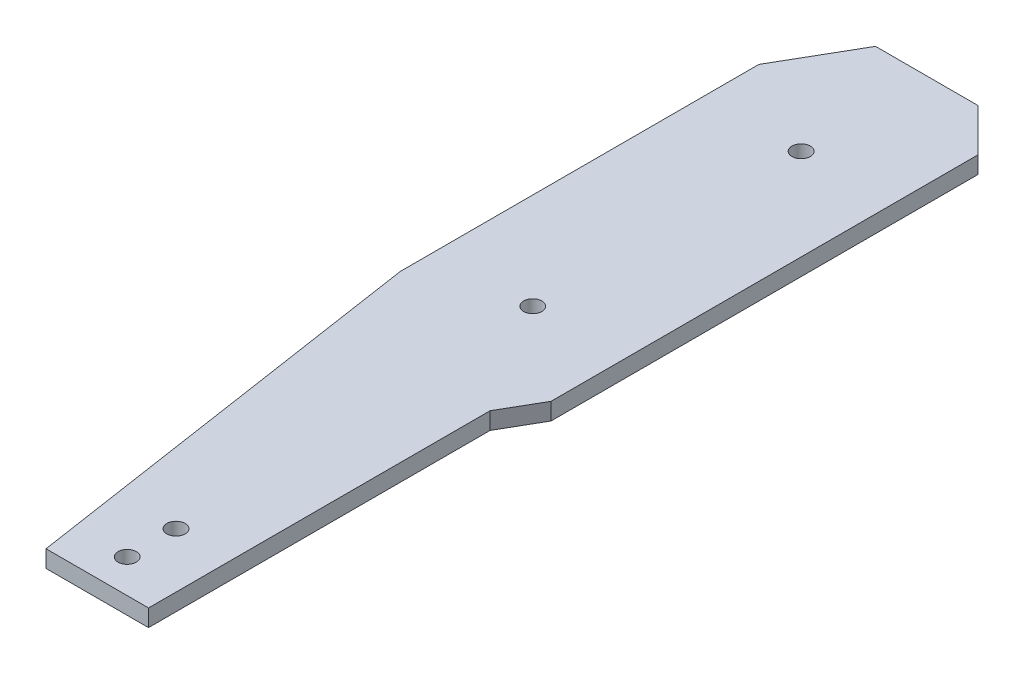
from build123d import *

# Parameters (mm, degrees)
BOSS_EXTRUDE1_DEPTH = 2
SCALE1_SCALE        = 1.4
SKETCH2_R           = 1.5
CUT_EXTRUDE1_DEPTH  = 3.8
SKETCH3_R           = 1.5
CUT_EXTRUDE2_DEPTH  = 3.8


with BuildPart() as part:
    # Sketch1 → Boss-Extrude1 (new body)
    with BuildSketch(Plane(origin=(0, 0, 0), x_dir=(1, 0, 0), z_dir=(0, 1, 0))):
        Polygon((1.719047443, 61.234571581), (-10.280952557, 61.234571581), (-15.280952557, 52.574317544), (-15.280952557, 10.574317544), (-7.901694864, -38.292126086), (4.105557327, -38.292126086), (4.105557327, 1.707873914), (6.719047443, 6.234571581), (6.719047443, 56.234571581), align=None)
    extrude(amount=BOSS_EXTRUDE1_DEPTH)


with BuildPart() as part_1:
    # Scale1: scaled about (-3.98494468, 1, -15.536034959)
    add(part.part.scale(SCALE1_SCALE).moved(Location((1.593977872, -0.4, 6.214413984))))

    # Sketch2 → Cut-Extrude1 (cut, through all)
    with BuildSketch(Plane(origin=(0, 2.4, 0), x_dir=(1, 0, 0), z_dir=(0, 1, 0))):
        with Locations((-3.999355707, 14.51398623)):
            Circle(SKETCH2_R)
        with Locations((-3.999355707, 58.51398623)):
            Circle(SKETCH2_R)
    extrude(amount=-CUT_EXTRUDE1_DEPTH, mode=Mode.SUBTRACT)

    # Sketch3 → Cut-Extrude2 (cut, through all)
    with BuildSketch(Plane(origin=(0, 2.4, 0), x_dir=(1, 0, 0), z_dir=(0, 1, 0))):
        with Locations((-1.658241871, -46.323390503)):
            Circle(SKETCH3_R)
        with Locations((-1.658241871, -54.323390503)):
            Circle(SKETCH3_R)
    extrude(amount=-CUT_EXTRUDE2_DEPTH, mode=Mode.SUBTRACT)


solid = part_1.part
